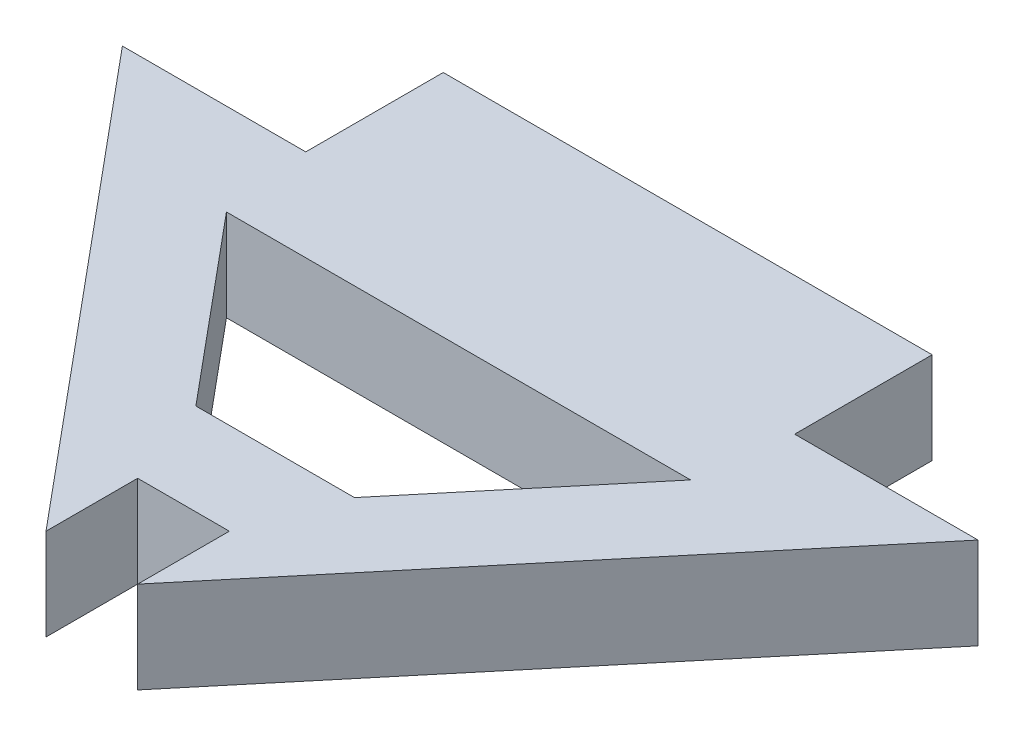
from build123d import *

# Parameters (mm, degrees)
BOSS_EXTRUDE1_DEPTH = 3


with BuildPart() as part:
    # Sketch1 → Boss-Extrude1 (new body)
    with BuildSketch(Plane(origin=(0, 0, 0), x_dir=(1, 0, 0), z_dir=(0, 1, 0))):
        Polygon((22.079481216, 3.028725772), (16.079481216, 3.028725772), (16.079481216, 7.528725772), (0.079481216, 7.528725772), (0.079481216, 3.028725772), (-5.920518784, 3.028725772), (6.579481216, -11.971274228), (6.579481216, -8.971274228), (9.579481216, -8.971274228), (9.579481216, -11.971274228), align=None)
        Polygon((15.674356378, 0.028725772), (0.484606054, 0.028725772), (5.484606054, -5.971274228), (10.674356378, -5.971274228), align=None, mode=Mode.SUBTRACT)
    extrude(amount=BOSS_EXTRUDE1_DEPTH)


solid = part.part
